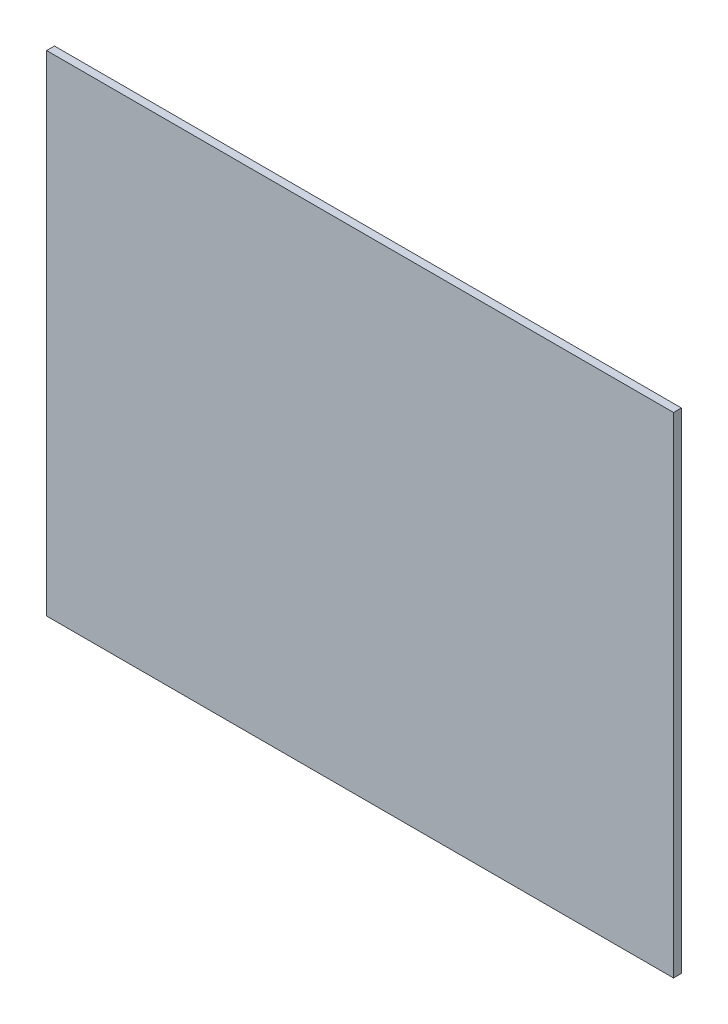
from build123d import *

# Parameters (mm, degrees)
ESBO_O1_W                = 160
ESBO_O1_H                = 125
RESSALTO_EXTRUS_O1_DEPTH = 2


with BuildPart() as part:
    # Esboço1 → Ressalto-extrusão1 (new body)
    with BuildSketch(Plane.XY):
        with Locations((-27.632364328, -85.527068541)):
            Rectangle(ESBO_O1_W, ESBO_O1_H)
    extrude(amount=RESSALTO_EXTRUS_O1_DEPTH)


solid = part.part
